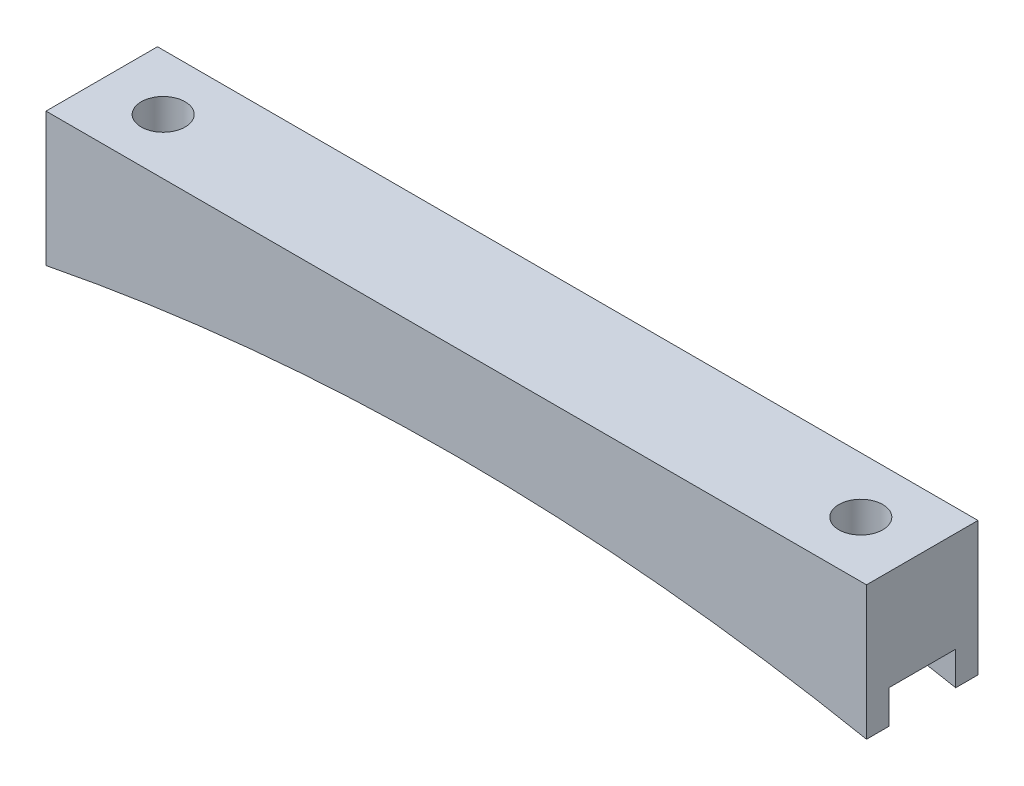
from build123d import *

# Parameters (mm, degrees)
BOSS_EXTRUDE1_DEPTH = 12.7
SKETCH2_R           = 2.5
CUT_EXTRUDE1_DEPTH  = 16.24
SKETCH3_W           = 7.62
SKETCH3_H           = 3.81
CUT_EXTRUDE2_DEPTH  = 94.4700001


with BuildPart() as part:
    # Sketch1 → Boss-Extrude1 (new body)
    with BuildSketch(Plane.XY):
        with BuildLine():
            Line((-46.735, 0), (46.735, 0))
            Line((46.735, 0), (46.735, -15.24))
            ThreePointArc((46.735, -15.24), (0, -10.670922727), (-46.735, -15.24))
            Line((-46.735, -15.24), (-46.735, 0))
        make_face()
    extrude(amount=BOSS_EXTRUDE1_DEPTH)

    # Sketch2 → Cut-Extrude1 (cut, through all)
    with BuildSketch(Plane(origin=(0, 0, 0), x_dir=(1, 0, 0), z_dir=(0, 1, 0))):
        with Locations((-39.735, -6.35)):
            Circle(SKETCH2_R)
        with Locations((39.735, -6.35)):
            Circle(SKETCH2_R)
    extrude(amount=-CUT_EXTRUDE1_DEPTH, mode=Mode.SUBTRACT)

    # Sketch3 → Cut-Extrude2 (cut, through all)
    with BuildSketch(Plane(origin=(46.735, 0, 0), x_dir=(0, 0, -1), z_dir=(1, 0, 0))):
        with Locations((-6.35, -13.335)):
            Rectangle(SKETCH3_W, SKETCH3_H)
    extrude(amount=-CUT_EXTRUDE2_DEPTH, mode=Mode.SUBTRACT)


solid = part.part
